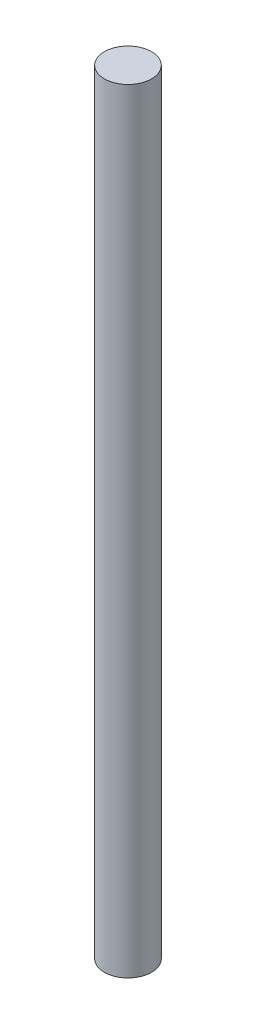
from build123d import *

# Parameters (mm, degrees)
SKETCH1_R           = 152.4
BOSS_EXTRUDE1_DEPTH = 5000


with BuildPart() as part:
    # Sketch1 → Boss-Extrude1 (new body)
    with BuildSketch(Plane(origin=(0, 0, 0), x_dir=(1, 0, 0), z_dir=(0, 1, 0))):
        Circle(SKETCH1_R)
    extrude(amount=BOSS_EXTRUDE1_DEPTH)


solid = part.part
